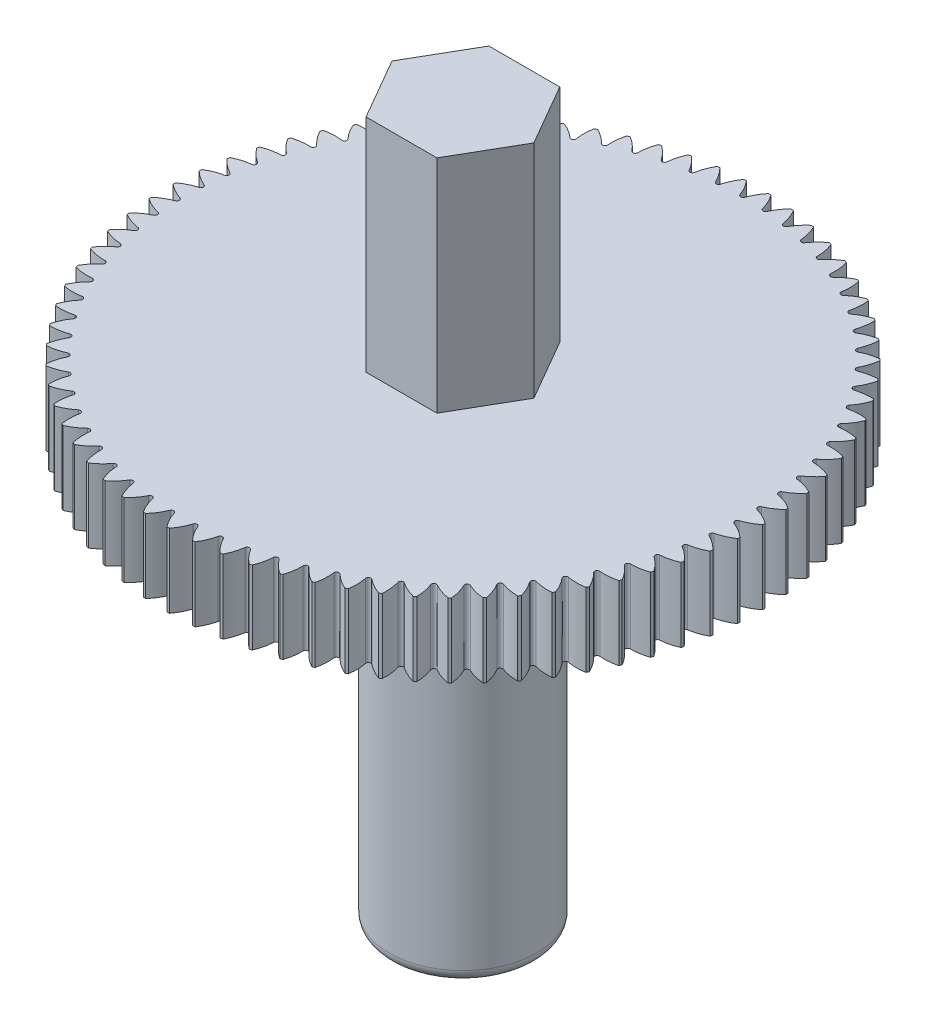
from build123d import *

# Parameters (mm, degrees)
FILLET1_R          = 0.5
SKETCH2_R          = 3
CUT_EXTRUDE1_DEPTH = 9
CUT_EXTRUDE2_DEPTH = 4
CIRPATTERN1_COUNT  = 75


with BuildPart() as part:
    # Sketch1 → Revolve1 (revolve)
    with BuildSketch(Plane.XY):
        Polygon((0, 0), (0, 29), (3, 29), (3, 20), (12, 20), (12, 17), (3, 17), (3, 0), align=None)
    revolve(axis=Axis((0, 0, 0), (0, 1, 0)))

    # Fillet1
    fillet1_edges = [part.edges().sort_by_distance(p)[0] for p in [
        (-3, 0, 0),
    ]]
    fillet(fillet1_edges, radius=FILLET1_R)

    # Sketch2 → Cut-Extrude1 (cut)
    with BuildSketch(Plane(origin=(0, 29, 0), x_dir=(1, 0, 0), z_dir=(0, 1, 0))):
        Circle(SKETCH2_R)
        Polygon((1.443375673, -2.5), (2.886751346, 0), (1.443375673, 2.5), (-1.443375673, 2.5), (-2.886751346, 0), (-1.443375673, -2.5), align=None, mode=Mode.SUBTRACT)
    extrude(amount=-CUT_EXTRUDE1_DEPTH, mode=Mode.SUBTRACT)

    # Sketch3 → Cut-Extrude2 (cut)
    with BuildSketch(Plane(origin=(0, 20, 0), x_dir=(1, 0, 0), z_dir=(0, 1, 0))):
        with BuildLine():
            ThreePointArc((0.45, 11.991559532), (0, 12), (-0.45, 11.991559532))
            ThreePointArc((-0.45, 11.991559532), (-0.244185037, 11.69752696), (-0.094236566, 11.371443523))
            ThreePointArc((-0.094236566, 11.371443523), (0, 11.304902), (0.094236566, 11.371443523))
            ThreePointArc((0.094236566, 11.371443523), (0.244185037, 11.69752696), (0.45, 11.991559532))
        make_face()
    cut_extrude2 = extrude(amount=-CUT_EXTRUDE2_DEPTH, mode=Mode.SUBTRACT)

    # CirPattern1: Cut-Extrude2 ×75 about axis
    cirpattern1_axis = Axis((0, 0, 0), (0, 1, 0))
    for i in range(1, CIRPATTERN1_COUNT):
        add(cut_extrude2.rotate(cirpattern1_axis, i * 360 / CIRPATTERN1_COUNT), mode=Mode.SUBTRACT)


solid = part.part
